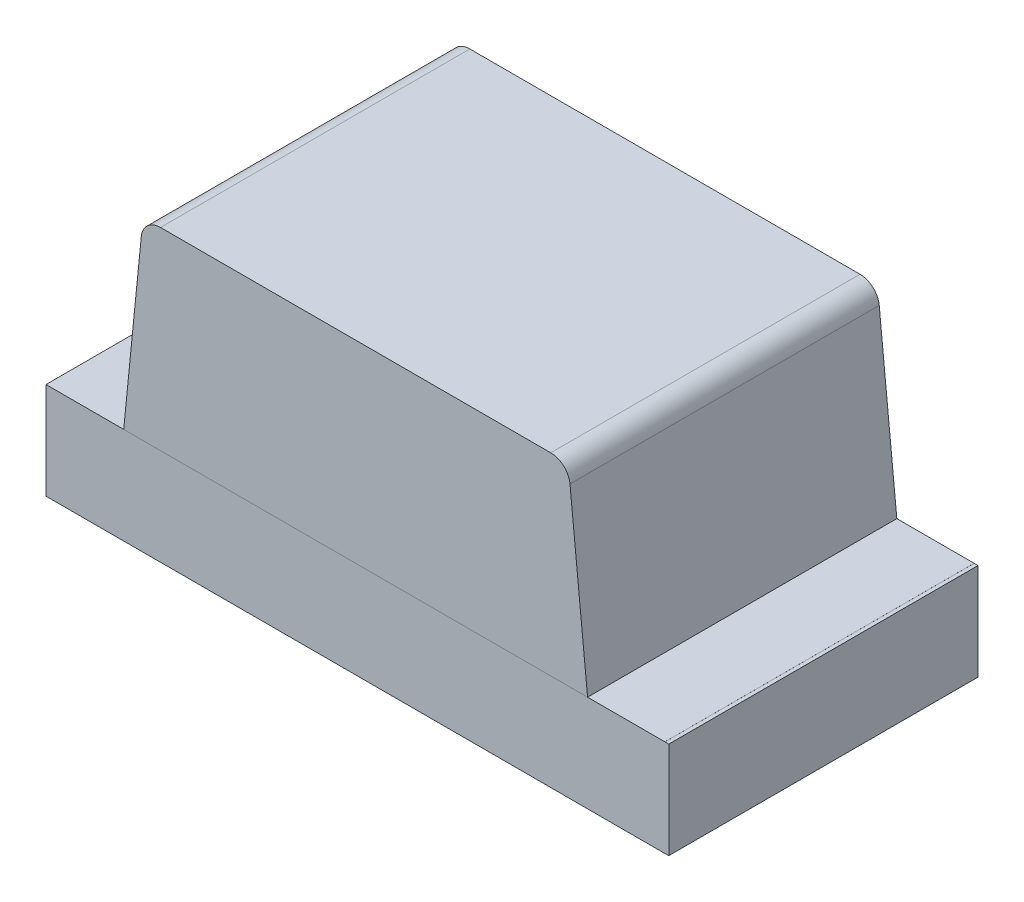
from build123d import *

# Parameters (mm, degrees)
SKETCH1_W             = 1.6
SKETCH1_H             = 0.25
EXTRUDE1_DEPTH        = 0.4
EXTRUDE2_DEPTH        = 0.4
EXTRUDE3_DEPTH        = 0.0001
EXTRUDE3_DEPTH_BACK   = 0.01
SKETCH2_3_W           = 0.3
SKETCH2_3_H           = 0.8
EXTRUDE4_DEPTH        = 0.0001
EXTRUDE4_DEPTH_BACK   = 0.01
EXTRUDE4_2_DEPTH      = 0.0001
EXTRUDE4_2_DEPTH_BACK = 0.01
SKETCH3_W             = 0.2
SKETCH3_H             = 0.8
EXTRUDE5_DEPTH        = 0.0001
EXTRUDE5_DEPTH_BACK   = 0.01
EXTRUDE5_2_DEPTH      = 0.0001
EXTRUDE5_2_DEPTH_BACK = 0.01
FILLET1_R             = 0.05
SKETCH5_W             = 0.8
SKETCH5_H             = 0.25
EXTRUDE6_DEPTH        = 0.01
EXTRUDE6_DEPTH_BACK   = 0.0001
SKETCH6_W             = 0.8
SKETCH6_H             = 0.2502
EXTRUDE7_DEPTH        = 0.001
EXTRUDE7_DEPTH_BACK   = 0.01
SKETCH7_W             = 0.013291139
SKETCH7_H             = 0.012658227
SKETCH7_H_2           = 0.012658228
CUT_EXTRUDE1_DEPTH    = 0.01


with BuildPart() as part:
    # Sketch1 → Extrude1 (new, symmetric)
    with BuildSketch(Plane.XY):
        Rectangle(SKETCH1_W, SKETCH1_H)
    extrude(amount=EXTRUDE1_DEPTH, both=True)



with BuildPart() as body_2:
    # Sketch1_3 → Extrude2 (new, symmetric)
    with BuildSketch(Plane.XY):
        Polygon((-0.55, 0.625), (-0.6, 0.125), (0.6, 0.125), (0.55, 0.625), align=None)
    extrude(amount=EXTRUDE2_DEPTH, both=True)

    # Fillet1
    fillet1_edges = [body_2.edges().sort_by_distance(p)[0] for p in [
        (-0.55, 0.625, 0),
        (0.55, 0.625, 0),
    ]]
    fillet(fillet1_edges, radius=FILLET1_R)


with BuildPart() as body_3:
    # Sketch2 → Extrude3 (new, two sides)
    with BuildSketch(Plane.XZ.offset(0.125)) as extrude3_sk:
        Polygon((-0.339833711, 0.4), (-0.339833711, -0.4), (0.32532124, 0), align=None)
    extrude(amount=EXTRUDE3_DEPTH)
    extrude(extrude3_sk.sketch, amount=-EXTRUDE3_DEPTH_BACK)


with BuildPart() as body_4:
    # Sketch2_3 → Extrude4 (new, two sides)
    with BuildSketch(Plane.XZ.offset(0.125)) as extrude4_sk:
        with Locations((-0.65, 0)):
            Rectangle(SKETCH2_3_W, SKETCH2_3_H)
    extrude(amount=EXTRUDE4_DEPTH)
    extrude(extrude4_sk.sketch, amount=-EXTRUDE4_DEPTH_BACK)


with BuildPart() as body_5:
    # Sketch2_3 → Extrude4 2 (new, two sides)
    with BuildSketch(Plane.XZ.offset(0.125)) as extrude4_2_sk:
        with Locations((0.65, 0)):
            Rectangle(SKETCH2_3_W, SKETCH2_3_H)
    extrude(amount=EXTRUDE4_2_DEPTH)
    extrude(extrude4_2_sk.sketch, amount=-EXTRUDE4_2_DEPTH_BACK)


with BuildPart() as body_6:
    # Sketch3 → Extrude5 (new, two sides)
    with BuildSketch(Plane(origin=(0, 0.125, 0), x_dir=(-1, 0, 0), z_dir=(0, 1, 0))) as extrude5_sk:
        with Locations((0.7, 0)):
            Rectangle(SKETCH3_W, SKETCH3_H)
    extrude(amount=EXTRUDE5_DEPTH)
    extrude(extrude5_sk.sketch, amount=-EXTRUDE5_DEPTH_BACK)


with BuildPart() as body_7:
    # Sketch3 → Extrude5 2 (new, two sides)
    with BuildSketch(Plane(origin=(0, 0.125, 0), x_dir=(-1, 0, 0), z_dir=(0, 1, 0))) as extrude5_2_sk:
        with Locations((-0.7, 0)):
            Rectangle(SKETCH3_W, SKETCH3_H)
    extrude(amount=EXTRUDE5_2_DEPTH)
    extrude(extrude5_2_sk.sketch, amount=-EXTRUDE5_2_DEPTH_BACK)


with BuildPart() as part_1:
    add(part.part)

    add(body_5.part)  # Extrude6 merges body 5

    add(body_7.part)  # Extrude6 merges body 7
    # Sketch5 → Extrude6 (add, two sides)
    with BuildSketch(Plane(origin=(0.8, 0, 0), x_dir=(0, 0, -1), z_dir=(1, 0, 0))) as extrude6_sk:
        Rectangle(SKETCH5_W, SKETCH5_H)
    extrude(amount=EXTRUDE6_DEPTH)
    extrude(extrude6_sk.sketch, amount=-EXTRUDE6_DEPTH_BACK)


    add(body_4.part)  # Extrude7 merges body 4

    add(body_6.part)  # Extrude7 merges body 6
    # Sketch6 → Extrude7 (add, two sides)
    with BuildSketch(Plane.ZY.offset(0.8)) as extrude7_sk:
        Rectangle(SKETCH6_W, SKETCH6_H)
    extrude(amount=EXTRUDE7_DEPTH)
    extrude(extrude7_sk.sketch, amount=-EXTRUDE7_DEPTH_BACK)

    # Sketch7 → Cut-Extrude1 (cut)
    with BuildSketch(Plane.XZ.offset(0.1251)):
        Polygon((-0.707001992, 0.286075949), (-0.744343764, 0.297804589), (-0.744343764, 0.310176028), (-0.719175647, 0.318384098), (-0.744343764, 0.326147152), (-0.744343764, 0.339013054), (-0.707001992, 0.350632911), (-0.707001992, 0.338043908), (-0.732743685, 0.331546677), (-0.707001992, 0.323338608), (-0.707001992, 0.312589003), (-0.732743685, 0.30443038), (-0.707001992, 0.298022152), align=None)
        Polygon((-0.707001992, 0.218987342), (-0.744343764, 0.230715981), (-0.744343764, 0.243087421), (-0.719175647, 0.251295491), (-0.744343764, 0.259058544), (-0.744343764, 0.271924446), (-0.707001992, 0.283544304), (-0.707001992, 0.270955301), (-0.732743685, 0.26445807), (-0.707001992, 0.25625), (-0.707001992, 0.245500396), (-0.732743685, 0.237341772), (-0.707001992, 0.230933544), align=None)
        Polygon((-0.707001992, 0.151898734), (-0.744343764, 0.163627373), (-0.744343764, 0.175998813), (-0.719175647, 0.184206883), (-0.744343764, 0.191969937), (-0.744343764, 0.204835839), (-0.707001992, 0.216455696), (-0.707001992, 0.203866693), (-0.732743685, 0.197369462), (-0.707001992, 0.189161392), (-0.707001992, 0.178411788), (-0.732743685, 0.170253165), (-0.707001992, 0.163844937), align=None)
        with Locations((-0.737698195, 0.137974684)):
            Rectangle(SKETCH7_W, SKETCH7_H)
        with BuildLine():
            add(Edge.make_bspline(
                [(-0.728758321, 0.079746835), (-0.729369388, 0.079765085), (-0.73056932, 0.07980092), (-0.732323163, 0.080105713), (-0.733985315, 0.080602697), (-0.735567388, 0.081288866), (-0.737052132, 0.082185594), (-0.738453578, 0.08327723), (-0.73975585, 0.084571671), (-0.740974038, 0.086045073), (-0.742065093, 0.087693545), (-0.74301811, 0.089492402), (-0.743815446, 0.091432415), (-0.744484978, 0.093506521), (-0.744979195, 0.095729794), (-0.745341189, 0.098088543), (-0.745577848, 0.100585257), (-0.745598831, 0.102297046), (-0.745609587, 0.103174446)],
                knots=[0, 0, 0, 0, 0.907312236, 1.78165839, 2.635367075, 3.479697475, 4.336364812, 5.205276731, 6.11257575, 7.058770404, 8.040786331, 9.044147278, 10.078219212, 11.153049307, 12.278104542, 13.457648573, 14.696882856, 16, 16, 16, 16], degree=3))
            add(Edge.make_bspline(
                [(-0.745609587, 0.103174446), (-0.745597551, 0.104183574), (-0.745574239, 0.106138165), (-0.745359939, 0.108969928), (-0.74503687, 0.111603946), (-0.744553599, 0.114051804), (-0.743953216, 0.116354103), (-0.74330757, 0.118570737), (-0.742575363, 0.120711393), (-0.742025284, 0.122097938), (-0.741752783, 0.12278481)],
                knots=[0, 0, 0, 0, 1.203215828, 2.33052265, 3.384689099, 4.366106119, 5.303329643, 6.221311756, 7.118865988, 8, 8, 8, 8], degree=3))
            Line((-0.741752783, 0.12278481), (-0.729786802, 0.12278481))
            Line((-0.729786802, 0.12278481), (-0.729786802, 0.121360759))
            add(Edge.make_bspline(
                [(-0.729786802, 0.121360759), (-0.73032753, 0.120678102), (-0.73140581, 0.119316796), (-0.732787113, 0.11710018), (-0.733988194, 0.114776357), (-0.734975195, 0.112353621), (-0.735768357, 0.109905199), (-0.736315121, 0.10746751), (-0.736688795, 0.105084716), (-0.736729049, 0.103505432), (-0.736748828, 0.10272943)],
                knots=[0, 0, 0, 0, 1.030622468, 2.055194264, 3.087043286, 4.125157485, 5.149848264, 6.130935704, 7.081611712, 8, 8, 8, 8], degree=3))
            add(Edge.make_bspline(
                [(-0.736748828, 0.10272943), (-0.73674838, 0.102515041), (-0.736747423, 0.10205605), (-0.736683001, 0.101322032), (-0.73663642, 0.100492732), (-0.736531811, 0.099603299), (-0.736422519, 0.09870789), (-0.736232359, 0.09788056), (-0.73605144, 0.097128741), (-0.735867351, 0.0966755), (-0.735779682, 0.096459652)],
                knots=[0, 0, 0, 0, 0.806378557, 1.726393851, 2.771014456, 3.931269413, 5.096090628, 6.161710732, 7.124547685, 8, 8, 8, 8], degree=3))
            add(Edge.make_bspline(
                [(-0.735779682, 0.096459652), (-0.73566577, 0.096219758), (-0.735441909, 0.095748317), (-0.735033106, 0.095100857), (-0.734597455, 0.094509521), (-0.734114745, 0.093978791), (-0.733525791, 0.093553657), (-0.732825363, 0.093239557), (-0.732000213, 0.09306801), (-0.731412708, 0.093048363), (-0.731102071, 0.093037975)],
                knots=[0, 0, 0, 0, 1.024407818, 2.013179384, 2.949802342, 3.859052226, 4.77034807, 5.732977883, 6.801339628, 8, 8, 8, 8], degree=3))
            add(Edge.make_bspline(
                [(-0.731102071, 0.093037975), (-0.730829123, 0.093053696), (-0.730292427, 0.093084607), (-0.729528429, 0.093375503), (-0.72881749, 0.093816952), (-0.728187133, 0.094460463), (-0.727608414, 0.095257502), (-0.727123265, 0.09623537), (-0.726683228, 0.09736186), (-0.726474594, 0.098184089), (-0.726365125, 0.098615506)],
                knots=[0, 0, 0, 0, 0.825212765, 1.622611382, 2.449701629, 3.348069183, 4.336544339, 5.428209675, 6.6506027, 8, 8, 8, 8], degree=3))
            add(Edge.make_bspline(
                [(-0.726365125, 0.098615506), (-0.726141255, 0.09959987), (-0.72568266, 0.101616324), (-0.725109106, 0.104690378), (-0.72447607, 0.107755492), (-0.723871299, 0.109734848), (-0.723576359, 0.110700158)],
                knots=[0, 0, 0, 0, 0.976104583, 1.999535498, 3.024395274, 4, 4, 4, 4], degree=3))
            add(Edge.make_bspline(
                [(-0.723576359, 0.110700158), (-0.723399863, 0.111219416), (-0.723056296, 0.1122302), (-0.722475484, 0.113675972), (-0.721840508, 0.115006529), (-0.721162942, 0.116226584), (-0.720425943, 0.117326245), (-0.719659249, 0.11832384), (-0.71883233, 0.119195603), (-0.71796637, 0.119969445), (-0.717040369, 0.120631102), (-0.7160683, 0.121208477), (-0.715038068, 0.121696295), (-0.713957424, 0.122100736), (-0.712817989, 0.122409273), (-0.711629552, 0.122619901), (-0.710387872, 0.122769095), (-0.709540696, 0.122779501), (-0.7091084, 0.12278481)],
                knots=[0, 0, 0, 0, 1.287286806, 2.505824366, 3.654938963, 4.74627059, 5.778586806, 6.75996495, 7.696030012, 8.595059759, 9.482019644, 10.363222407, 11.245851011, 12.154256429, 13.068444161, 14.012503255, 14.985824751, 16, 16, 16, 16], degree=3))
            add(Edge.make_bspline(
                [(-0.7091084, 0.12278481), (-0.708530328, 0.122766159), (-0.707392692, 0.122729454), (-0.70572817, 0.12242874), (-0.704153801, 0.121915445), (-0.70265207, 0.121222413), (-0.701245527, 0.120308099), (-0.699906253, 0.119215702), (-0.698670457, 0.117903678), (-0.697520291, 0.116415118), (-0.696480591, 0.114771425), (-0.695565313, 0.113001934), (-0.694796987, 0.111117289), (-0.69416004, 0.109124516), (-0.693682705, 0.107015281), (-0.693323239, 0.104796665), (-0.693116648, 0.102459771), (-0.693091023, 0.10086406), (-0.693077942, 0.100049446)],
                knots=[0, 0, 0, 0, 0.894990994, 1.761326291, 2.609044902, 3.454222546, 4.315366365, 5.200560057, 6.125081389, 7.100429509, 8.110379559, 9.133447974, 10.182136699, 11.259192205, 12.370181258, 13.528580438, 14.738335141, 16, 16, 16, 16], degree=3))
            add(Edge.make_bspline(
                [(-0.693077942, 0.100049446), (-0.693089037, 0.099215103), (-0.69311121, 0.09754783), (-0.693300199, 0.095057109), (-0.693577813, 0.092576858), (-0.693998666, 0.090144943), (-0.694486874, 0.087799665), (-0.695034772, 0.085593047), (-0.695653754, 0.083553317), (-0.696130927, 0.082266485), (-0.696361169, 0.08164557)],
                knots=[0, 0, 0, 0, 1.065403572, 2.129000689, 3.188532477, 4.251604565, 5.279552602, 6.247508681, 7.154397237, 8, 8, 8, 8], degree=3))
            Line((-0.696361169, 0.08164557), (-0.707634904, 0.08164557))
            Line((-0.707634904, 0.08164557), (-0.707634904, 0.083059731))
            add(Edge.make_bspline(
                [(-0.707634904, 0.083059731), (-0.70723473, 0.083596183), (-0.706416365, 0.084693243), (-0.705374529, 0.086523061), (-0.704395596, 0.088502179), (-0.703553517, 0.090641594), (-0.702823776, 0.092871108), (-0.702314193, 0.095162587), (-0.701993288, 0.097475669), (-0.701956901, 0.099026524), (-0.701938701, 0.099802215)],
                knots=[0, 0, 0, 0, 0.892283326, 1.824742884, 2.804416662, 3.836872171, 4.8899239, 5.931447339, 6.965372909, 8, 8, 8, 8], degree=3))
            add(Edge.make_bspline(
                [(-0.701938701, 0.099802215), (-0.701949427, 0.100350049), (-0.701970878, 0.101445657), (-0.70216622, 0.103079762), (-0.702481667, 0.104700792), (-0.702891308, 0.105721053), (-0.703095742, 0.106230222)],
                knots=[0, 0, 0, 0, 0.999146175, 1.998183711, 3.000980573, 4, 4, 4, 4], degree=3))
            add(Edge.make_bspline(
                [(-0.703095742, 0.106230222), (-0.703196476, 0.106446973), (-0.703397875, 0.106880332), (-0.703784157, 0.107483654), (-0.704248563, 0.108035989), (-0.704774559, 0.108532027), (-0.705352745, 0.108966226), (-0.705990159, 0.109273902), (-0.706671616, 0.109461838), (-0.707139231, 0.109482917), (-0.707377783, 0.109493671)],
                knots=[0, 0, 0, 0, 1.00524851, 2.009826503, 3.004679593, 4.035271301, 5.048246368, 6.034938417, 6.997532266, 8, 8, 8, 8], degree=3))
            add(Edge.make_bspline(
                [(-0.707377783, 0.109493671), (-0.707696866, 0.109476452), (-0.708306604, 0.109443548), (-0.709164502, 0.109140256), (-0.709903719, 0.108647839), (-0.710401179, 0.108067536), (-0.710749898, 0.107508972), (-0.711005153, 0.106991142), (-0.711246832, 0.106386528), (-0.711495567, 0.105700905), (-0.71174116, 0.104932741), (-0.711978934, 0.104078462), (-0.712203582, 0.103137104), (-0.712346677, 0.102479167), (-0.712421296, 0.102136076)],
                knots=[0, 0, 0, 0, 1.173816843, 2.243057204, 3.312297565, 4.415174738, 5.03266065, 5.73970059, 6.541434878, 7.433956553, 8.430083051, 9.515931566, 10.70464786, 12, 12, 12, 12], degree=3))
            add(Edge.make_bspline(
                [(-0.712421296, 0.102136076), (-0.712609327, 0.101219681), (-0.712978766, 0.099419168), (-0.71353051, 0.096718577), (-0.714167994, 0.09396719), (-0.714742396, 0.092134526), (-0.715041945, 0.091178797)],
                knots=[0, 0, 0, 0, 0.995744513, 1.956417928, 2.934277412, 4, 4, 4, 4], degree=3))
            add(Edge.make_bspline(
                [(-0.715041945, 0.091178797), (-0.715201567, 0.09070552), (-0.715513813, 0.089779714), (-0.716056954, 0.088459399), (-0.716643946, 0.087235869), (-0.717264711, 0.086102353), (-0.717936694, 0.085065368), (-0.718648018, 0.084118027), (-0.719411472, 0.083276117), (-0.720218086, 0.082527335), (-0.721073136, 0.081867755), (-0.721992673, 0.081301606), (-0.722967074, 0.080815492), (-0.724010174, 0.080430689), (-0.725107467, 0.080121679), (-0.726273151, 0.079910131), (-0.72749534, 0.079763139), (-0.728332628, 0.079752331), (-0.728758321, 0.079746835)],
                knots=[0, 0, 0, 0, 1.237467875, 2.420686895, 3.535046182, 4.599015201, 5.620884487, 6.594603852, 7.531477383, 8.433220087, 9.318759595, 10.202828513, 11.105163009, 12.01247538, 12.953896178, 13.926381251, 14.945733412, 16, 16, 16, 16], degree=3))
        make_face()
        with BuildLine():
            Line((-0.744343764, 0.033544304), (-0.744343764, 0.04556962))
            Line((-0.744343764, 0.04556962), (-0.740427625, 0.04556962))
            add(Edge.make_bspline(
                [(-0.740427625, 0.04556962), (-0.740831904, 0.046116275), (-0.741611349, 0.047170216), (-0.742651457, 0.048756729), (-0.74353909, 0.050269774), (-0.744318701, 0.051726519), (-0.744906393, 0.053237621), (-0.745320427, 0.054853378), (-0.745570313, 0.05660479), (-0.745596205, 0.057818238), (-0.745609587, 0.058445411)],
                knots=[0, 0, 0, 0, 1.150872466, 2.218865267, 3.209461834, 4.120482262, 5.012764827, 5.946708227, 6.938749913, 8, 8, 8, 8], degree=3))
            add(Edge.make_bspline(
                [(-0.745609587, 0.058445411), (-0.745598228, 0.058953587), (-0.745576107, 0.059943153), (-0.745403669, 0.061381773), (-0.745134843, 0.062735587), (-0.744731047, 0.063993106), (-0.744248146, 0.065175101), (-0.743608167, 0.066243876), (-0.74289308, 0.067245677), (-0.742039557, 0.068136513), (-0.74109069, 0.068944324), (-0.74002446, 0.069635599), (-0.738857998, 0.070224454), (-0.737582071, 0.070695003), (-0.736202919, 0.071072548), (-0.734713295, 0.071334514), (-0.733119731, 0.07149481), (-0.732022166, 0.07151078), (-0.731458084, 0.071518987)],
                knots=[0, 0, 0, 0, 1.109008058, 2.159558935, 3.158726032, 4.116861086, 5.039058877, 5.938775559, 6.82970133, 7.720510853, 8.624361809, 9.544451588, 10.487360536, 11.471068125, 12.508000841, 13.604731202, 14.768976642, 16, 16, 16, 16], degree=3))
            Line((-0.731458084, 0.071518987), (-0.707001992, 0.071518987))
            Line((-0.707001992, 0.071518987), (-0.707001992, 0.059493671))
            Line((-0.707001992, 0.059493671), (-0.725791549, 0.059493671))
            add(Edge.make_bspline(
                [(-0.725791549, 0.059493671), (-0.726249785, 0.059492853), (-0.727126892, 0.059491288), (-0.728379796, 0.059450118), (-0.729513882, 0.059389668), (-0.730534896, 0.059320316), (-0.731458272, 0.059193807), (-0.732291352, 0.059004953), (-0.733051153, 0.05876954), (-0.733504504, 0.058537381), (-0.73372272, 0.058425633)],
                knots=[0, 0, 0, 0, 1.361401701, 2.605856924, 3.723918663, 4.735739235, 5.645738665, 6.489217889, 7.27279937, 8, 8, 8, 8], degree=3))
            add(Edge.make_bspline(
                [(-0.73372272, 0.058425633), (-0.733922077, 0.05831063), (-0.734313997, 0.058084543), (-0.734817086, 0.057624398), (-0.73523922, 0.057085026), (-0.735567234, 0.056446225), (-0.735816709, 0.055702951), (-0.735986827, 0.054838985), (-0.736094578, 0.053846304), (-0.736108532, 0.053141795), (-0.736115916, 0.052768987)],
                knots=[0, 0, 0, 0, 0.849138082, 1.669332372, 2.503455908, 3.370611167, 4.311442699, 5.394692208, 6.621337967, 8, 8, 8, 8], degree=3))
            add(Edge.make_bspline(
                [(-0.736115916, 0.052768987), (-0.736107238, 0.052498345), (-0.736089394, 0.051941887), (-0.735973171, 0.05108623), (-0.735794834, 0.050187942), (-0.735464906, 0.04893065), (-0.734871816, 0.047347337), (-0.734194613, 0.046167686), (-0.73385128, 0.04556962)],
                knots=[0, 0, 0, 0, 0.638127216, 1.312033637, 2.033062677, 2.79661882, 4.375931797, 6, 6, 6, 6], degree=3))
            Line((-0.73385128, 0.04556962), (-0.707001992, 0.04556962))
            Line((-0.707001992, 0.04556962), (-0.707001992, 0.033544304))
            Line((-0.707001992, 0.033544304), (-0.744343764, 0.033544304))
        make_face()
        with BuildLine():
            Line((-0.744343764, -0.015189873), (-0.744343764, -0.003164557))
            Line((-0.744343764, -0.003164557), (-0.725554207, -0.003164557))
            add(Edge.make_bspline(
                [(-0.725554207, -0.003164557), (-0.724789186, -0.0031523), (-0.723263673, -0.003127858), (-0.721382468, -0.002986796), (-0.719961306, -0.002797535), (-0.719042365, -0.002612707), (-0.718268296, -0.002396857), (-0.717825416, -0.002190717), (-0.717623036, -0.002096519)],
                knots=[0, 0, 0, 0, 1.709124929, 3.408128882, 4.211124727, 4.91016634, 5.501986363, 6, 6, 6, 6], degree=3))
            add(Edge.make_bspline(
                [(-0.717623036, -0.002096519), (-0.71742401, -0.001974288), (-0.71703379, -0.001734636), (-0.716527283, -0.001265974), (-0.716112863, -0.000719031), (-0.715772088, -8.3646e-05), (-0.715536797, 0.000661952), (-0.715340182, 0.001520323), (-0.715256728, 0.002513632), (-0.715239148, 0.003217267), (-0.71522984, 0.003589794)],
                knots=[0, 0, 0, 0, 0.86006424, 1.686277094, 2.52783008, 3.38194165, 4.331801563, 5.402842185, 6.624978739, 8, 8, 8, 8], degree=3))
            add(Edge.make_bspline(
                [(-0.71522984, 0.003589794), (-0.715258209, 0.004155705), (-0.715316136, 0.005311252), (-0.715671889, 0.006742349), (-0.716081369, 0.007907651), (-0.716460784, 0.008833913), (-0.716946505, 0.009788229), (-0.717307416, 0.010427935), (-0.717494476, 0.010759494)],
                knots=[0, 0, 0, 0, 1.338371478, 2.732853438, 3.468019217, 4.261884641, 5.099136535, 6, 6, 6, 6], degree=3))
            Line((-0.717494476, 0.010759494), (-0.744343764, 0.010759494))
            Line((-0.744343764, 0.010759494), (-0.744343764, 0.02278481))
            Line((-0.744343764, 0.02278481), (-0.707001992, 0.02278481))
            Line((-0.707001992, 0.02278481), (-0.707001992, 0.010759494))
            Line((-0.707001992, 0.010759494), (-0.710918131, 0.010759494))
            add(Edge.make_bspline(
                [(-0.710918131, 0.010759494), (-0.710515056, 0.01023079), (-0.709730445, 0.009201638), (-0.708710234, 0.007612019), (-0.70781085, 0.00607007), (-0.707054441, 0.004543565), (-0.706451054, 0.002986088), (-0.706045559, 0.001354709), (-0.705773658, -0.000353494), (-0.705748811, -0.001521852), (-0.705736169, -0.002116297)],
                knots=[0, 0, 0, 0, 1.126119141, 2.192057864, 3.198061997, 4.149848529, 5.076251285, 6.021887753, 6.99356175, 8, 8, 8, 8], degree=3))
            add(Edge.make_bspline(
                [(-0.705736169, -0.002116297), (-0.705748864, -0.002614433), (-0.705773646, -0.003586883), (-0.705928501, -0.005004263), (-0.706203833, -0.006339973), (-0.706602748, -0.00758611), (-0.707095554, -0.00875742), (-0.707711311, -0.009838393), (-0.708440523, -0.010834428), (-0.709271024, -0.011748628), (-0.710215887, -0.012564037), (-0.711274519, -0.013272555), (-0.712446068, -0.013862546), (-0.713726222, -0.014347902), (-0.715108777, -0.014735114), (-0.716606759, -0.014992679), (-0.718208849, -0.015169571), (-0.71931687, -0.015182971), (-0.719887673, -0.015189873)],
                knots=[0, 0, 0, 0, 1.08848837, 2.124922927, 3.110950502, 4.063144162, 4.979605775, 5.882838355, 6.774625441, 7.671951181, 8.57587277, 9.494821853, 10.448322275, 11.435533005, 12.482327682, 13.580118324, 14.753386918, 16, 16, 16, 16], degree=3))
            Line((-0.719887673, -0.015189873), (-0.744343764, -0.015189873))
        make_face()
        Polygon((-0.744343764, -0.062658228), (-0.744343764, -0.026582278), (-0.694343764, -0.026582278), (-0.694343764, -0.039240506), (-0.734850093, -0.039240506), (-0.734850093, -0.062658228), align=None)
        Polygon((-0.744343764, -0.106329114), (-0.744343764, -0.070253165), (-0.694343764, -0.070253165), (-0.694343764, -0.106329114), (-0.703837435, -0.106329114), (-0.703837435, -0.082911392), (-0.712698195, -0.082911392), (-0.712698195, -0.10443038), (-0.722191866, -0.10443038), (-0.722191866, -0.082911392), (-0.734850093, -0.082911392), (-0.734850093, -0.106329114), align=None)
        with BuildLine():
            add(Edge.make_bspline(
                [(-0.719393211, -0.164556962), (-0.719967055, -0.164547304), (-0.721103498, -0.164528178), (-0.722785901, -0.164380583), (-0.724418739, -0.16411757), (-0.726010863, -0.163777979), (-0.727550327, -0.163316726), (-0.729054116, -0.16277587), (-0.730506863, -0.162121047), (-0.73190758, -0.16136862), (-0.733243631, -0.160543884), (-0.734503736, -0.15965651), (-0.735695344, -0.15873362), (-0.736792791, -0.157738964), (-0.737813801, -0.156699373), (-0.738759208, -0.155611609), (-0.739610924, -0.154459076), (-0.740122366, -0.153655495), (-0.740378179, -0.15325356)],
                knots=[0, 0, 0, 0, 1.105570398, 2.18947457, 3.250358341, 4.290584537, 5.323553275, 6.344225964, 7.367641686, 8.3905646, 9.405808457, 10.390761353, 11.358902336, 12.307789878, 13.241960776, 14.165076779, 15.082208636, 16, 16, 16, 16], degree=3))
            add(Edge.make_bspline(
                [(-0.740378179, -0.15325356), (-0.740734249, -0.152633946), (-0.741448205, -0.151391556), (-0.7422825, -0.149399639), (-0.742984558, -0.147336898), (-0.74351177, -0.145161705), (-0.743875292, -0.1428382), (-0.744155696, -0.140337495), (-0.744306575, -0.1376337), (-0.744331085, -0.135766253), (-0.744343764, -0.134800237)],
                knots=[0, 0, 0, 0, 0.896288622, 1.797150563, 2.705281913, 3.629615989, 4.602417572, 5.655716007, 6.787320449, 8, 8, 8, 8], degree=3))
            Line((-0.744343764, -0.134800237), (-0.744343764, -0.117088608))
            Line((-0.744343764, -0.117088608), (-0.694343764, -0.117088608))
            Line((-0.694343764, -0.117088608), (-0.694343764, -0.135304589))
            add(Edge.make_bspline(
                [(-0.694343764, -0.135304589), (-0.69435207, -0.136293955), (-0.69436809, -0.138202319), (-0.694576885, -0.140960738), (-0.694875297, -0.143513342), (-0.695337733, -0.145856016), (-0.695895405, -0.148006019), (-0.69657497, -0.149968756), (-0.697324323, -0.151774643), (-0.69796117, -0.152864064), (-0.698269793, -0.153392009)],
                knots=[0, 0, 0, 0, 1.267175336, 2.444223962, 3.542125549, 4.557526608, 5.500936977, 6.385043188, 7.217374394, 8, 8, 8, 8], degree=3))
            add(Edge.make_bspline(
                [(-0.698269793, -0.153392009), (-0.698538063, -0.153817486), (-0.69907152, -0.154663548), (-0.699962446, -0.155864156), (-0.700940485, -0.156978869), (-0.701966394, -0.158043121), (-0.703067837, -0.15903303), (-0.704237191, -0.159954629), (-0.705476238, -0.160806538), (-0.706780972, -0.16158552), (-0.708145998, -0.162295927), (-0.709582528, -0.16289058), (-0.711071793, -0.163415255), (-0.712626274, -0.163818023), (-0.714230192, -0.16416698), (-0.715900864, -0.164384347), (-0.717627108, -0.164527653), (-0.718799553, -0.16454711), (-0.719393211, -0.164556962)],
                knots=[0, 0, 0, 0, 0.964065863, 1.917049184, 2.86229036, 3.805247319, 4.749389377, 5.698846072, 6.657678277, 7.629829384, 8.610569287, 9.604676042, 10.607940105, 11.6349849, 12.681042988, 13.752616828, 14.862056989, 16, 16, 16, 16], degree=3))
        make_face()
        with BuildLine():
            add(Edge.make_bspline(
                [(-0.719314097, -0.151265823), (-0.718911717, -0.151260702), (-0.718122425, -0.151250659), (-0.716964667, -0.151154875), (-0.715849842, -0.151025347), (-0.714782496, -0.15080982), (-0.713752711, -0.150559996), (-0.712773964, -0.150238922), (-0.711834177, -0.149876723), (-0.710945433, -0.149435904), (-0.710091242, -0.148949086), (-0.709298484, -0.148375339), (-0.708542041, -0.14775117), (-0.707828049, -0.147062027), (-0.707175101, -0.146290557), (-0.706560063, -0.145460506), (-0.7059959, -0.144560327), (-0.705665875, -0.143923833), (-0.705498828, -0.143601661)],
                knots=[0, 0, 0, 0, 1.152093354, 2.259898929, 3.325467225, 4.364140538, 5.376172865, 6.358396836, 7.312077728, 8.257828931, 9.196960457, 10.124297759, 11.056236784, 12.004246951, 12.961658638, 13.947279359, 14.960983522, 16, 16, 16, 16], degree=3))
            add(Edge.make_bspline(
                [(-0.705498828, -0.143601661), (-0.705345472, -0.143264213), (-0.705041509, -0.142595365), (-0.704675913, -0.141559954), (-0.704389495, -0.140515262), (-0.704174066, -0.139414463), (-0.704013101, -0.138179583), (-0.703914472, -0.136716792), (-0.703843387, -0.134988837), (-0.703839511, -0.13374548), (-0.703837435, -0.133079509)],
                knots=[0, 0, 0, 0, 0.826967603, 1.639107464, 2.447640171, 3.242670507, 4.14065217, 5.225198036, 6.513753944, 8, 8, 8, 8], degree=3))
            Line((-0.703837435, -0.133079509), (-0.703837435, -0.129746835))
            Line((-0.703837435, -0.129746835), (-0.734850093, -0.129746835))
            Line((-0.734850093, -0.129746835), (-0.734850093, -0.133079509))
            add(Edge.make_bspline(
                [(-0.734850093, -0.133079509), (-0.734847719, -0.133458613), (-0.734843134, -0.134190496), (-0.734821603, -0.135248617), (-0.734798159, -0.136231516), (-0.734739928, -0.137133951), (-0.734703605, -0.137963293), (-0.734614415, -0.138706684), (-0.734543325, -0.139377929), (-0.734409464, -0.140161727), (-0.734201372, -0.14108831), (-0.733862283, -0.14216894), (-0.733437085, -0.143239207), (-0.733094602, -0.143933494), (-0.732921692, -0.144284019)],
                knots=[0, 0, 0, 0, 1.186793418, 2.291178421, 3.313283093, 4.264083014, 5.122158624, 5.910777728, 6.607099052, 7.234812932, 8.398911528, 9.577194775, 10.776795607, 12, 12, 12, 12], degree=3))
            add(Edge.make_bspline(
                [(-0.732921692, -0.144284019), (-0.732750933, -0.144576577), (-0.732414176, -0.14515354), (-0.731847139, -0.145965292), (-0.731243277, -0.146719151), (-0.730599051, -0.147417157), (-0.729904931, -0.148048807), (-0.72917166, -0.148624816), (-0.728397671, -0.149140041), (-0.727300912, -0.149757735), (-0.725785444, -0.150369358), (-0.72380175, -0.15088913), (-0.721621869, -0.151207565), (-0.72010306, -0.151245906), (-0.719314097, -0.151265823)],
                knots=[0, 0, 0, 0, 0.755160452, 1.489275589, 2.205657296, 2.907868421, 3.605098304, 4.296256403, 4.985378686, 5.676536785, 7.100390329, 8.614249252, 10.241231541, 12, 12, 12, 12], degree=3))
        make_face(mode=Mode.SUBTRACT)
        with Locations((-0.737698195, -0.180379747)):
            Rectangle(SKETCH7_W, SKETCH7_H_2)
        with BuildLine():
            add(Edge.make_bspline(
                [(-0.745609587, -0.217701741), (-0.745598682, -0.216906684), (-0.745577276, -0.215346116), (-0.745338817, -0.213060445), (-0.74497997, -0.210877859), (-0.744469516, -0.208804705), (-0.743795768, -0.206847809), (-0.7429693, -0.20501599), (-0.741976708, -0.203312562), (-0.741187104, -0.202283238), (-0.740793527, -0.201770174)],
                knots=[0, 0, 0, 0, 1.123670284, 2.205584497, 3.245308791, 4.249063313, 5.220352711, 6.167273909, 7.086481357, 8, 8, 8, 8], degree=3))
            add(Edge.make_bspline(
                [(-0.740793527, -0.201770174), (-0.74036614, -0.2012943), (-0.739513018, -0.200344393), (-0.738027305, -0.199111426), (-0.736385783, -0.198049884), (-0.734584672, -0.197157107), (-0.732626307, -0.196441646), (-0.730503976, -0.195930079), (-0.728223586, -0.195620456), (-0.726649619, -0.195586873), (-0.725840995, -0.19556962)],
                knots=[0, 0, 0, 0, 0.916457077, 1.82937027, 2.759194969, 3.714948755, 4.706655623, 5.743329475, 6.840637961, 8, 8, 8, 8], degree=3))
            add(Edge.make_bspline(
                [(-0.725840995, -0.19556962), (-0.724989382, -0.195589), (-0.723338842, -0.195626562), (-0.720952748, -0.195958442), (-0.718743908, -0.196493248), (-0.716717954, -0.197262027), (-0.714871358, -0.198227248), (-0.71318544, -0.199359494), (-0.711663978, -0.200669757), (-0.710791259, -0.201673326), (-0.710354445, -0.202175633)],
                knots=[0, 0, 0, 0, 1.171797512, 2.271099083, 3.308930235, 4.294129479, 5.24602549, 6.17106565, 7.084581485, 8, 8, 8, 8], degree=3))
            add(Edge.make_bspline(
                [(-0.710354445, -0.202175633), (-0.709970152, -0.202688568), (-0.709196924, -0.203720634), (-0.708246574, -0.205422386), (-0.707449181, -0.207233994), (-0.706825359, -0.209148779), (-0.706348406, -0.211135184), (-0.705986484, -0.213165013), (-0.705776205, -0.21523814), (-0.705749579, -0.21663324), (-0.705736169, -0.217335839)],
                knots=[0, 0, 0, 0, 0.952130878, 1.915761808, 2.890227217, 3.891541892, 4.905612075, 5.925811839, 6.955400088, 8, 8, 8, 8], degree=3))
            add(Edge.make_bspline(
                [(-0.705736169, -0.217335839), (-0.705744671, -0.217959198), (-0.705761387, -0.219184934), (-0.705922441, -0.220985457), (-0.706189001, -0.222712728), (-0.706558302, -0.224365194), (-0.707004104, -0.225952167), (-0.707523674, -0.227477255), (-0.708090308, -0.228957161), (-0.708532576, -0.229907445), (-0.708752388, -0.230379747)],
                knots=[0, 0, 0, 0, 1.107648782, 2.178012834, 3.209595929, 4.211695017, 5.185427128, 6.137685403, 7.07440854, 8, 8, 8, 8], degree=3))
            Line((-0.708752388, -0.230379747), (-0.719027309, -0.230379747))
            Line((-0.719027309, -0.230379747), (-0.719027309, -0.228708465))
            add(Edge.make_bspline(
                [(-0.719027309, -0.228708465), (-0.718818699, -0.228458693), (-0.718367842, -0.227918875), (-0.717657465, -0.227025667), (-0.716892669, -0.225951196), (-0.716446696, -0.225124428), (-0.716208875, -0.224683544)],
                knots=[0, 0, 0, 0, 0.792826818, 1.713491785, 2.780691913, 4, 4, 4, 4], degree=3))
            add(Edge.make_bspline(
                [(-0.716208875, -0.224683544), (-0.715987896, -0.224219577), (-0.715534966, -0.223268604), (-0.715118549, -0.221990602), (-0.714834686, -0.220894601), (-0.714706475, -0.219985833), (-0.714611695, -0.219019023), (-0.714601941, -0.218351402), (-0.714596929, -0.218008307)],
                knots=[0, 0, 0, 0, 1.332524827, 2.731214173, 3.480270227, 4.267952375, 5.109889624, 6, 6, 6, 6], degree=3))
            add(Edge.make_bspline(
                [(-0.714596929, -0.218008307), (-0.714606704, -0.217625529), (-0.714625647, -0.216883724), (-0.714764175, -0.21580297), (-0.715003304, -0.214793764), (-0.715323354, -0.213842153), (-0.71576716, -0.212973121), (-0.716283979, -0.212159701), (-0.71689688, -0.211413572), (-0.717617351, -0.210753941), (-0.718407315, -0.210157578), (-0.719274373, -0.209647977), (-0.720197673, -0.209191749), (-0.721199897, -0.20884428), (-0.722264285, -0.208564411), (-0.723395845, -0.208369946), (-0.7245956, -0.208248967), (-0.725418754, -0.208235008), (-0.725840995, -0.208227848)],
                knots=[0, 0, 0, 0, 1.087302107, 2.107140881, 3.088415001, 4.030197574, 4.951552271, 5.852940509, 6.764198256, 7.685219758, 8.621679636, 9.570836121, 10.538340132, 11.542450476, 12.578202196, 13.66207107, 14.800746211, 16, 16, 16, 16], degree=3))
            add(Edge.make_bspline(
                [(-0.725840995, -0.208227848), (-0.726273074, -0.208235235), (-0.72711258, -0.208249588), (-0.728333385, -0.208366345), (-0.729474101, -0.208574291), (-0.730536761, -0.208859915), (-0.73151977, -0.209222089), (-0.732418468, -0.209674648), (-0.733246872, -0.210192826), (-0.733978178, -0.210815105), (-0.734636339, -0.211497047), (-0.735204406, -0.212254492), (-0.735678478, -0.213084112), (-0.73608071, -0.213975202), (-0.736369909, -0.214941723), (-0.736588255, -0.215969991), (-0.736732533, -0.217064769), (-0.736743315, -0.217819945), (-0.736748828, -0.218206092)],
                knots=[0, 0, 0, 0, 1.230336593, 2.390482092, 3.487897344, 4.52859895, 5.520747884, 6.465347575, 7.38981449, 8.296085817, 9.192433006, 10.084246191, 10.984321635, 11.908883871, 12.862027947, 13.850751296, 14.901019963, 16, 16, 16, 16], degree=3))
            add(Edge.make_bspline(
                [(-0.736748828, -0.218206092), (-0.736744764, -0.218569019), (-0.736736842, -0.219276532), (-0.736627803, -0.220308905), (-0.736489862, -0.221289359), (-0.736270158, -0.222207129), (-0.735998971, -0.223054762), (-0.735715717, -0.223834974), (-0.735413325, -0.224541197), (-0.735179548, -0.224971874), (-0.735067657, -0.225178006)],
                knots=[0, 0, 0, 0, 1.200823684, 2.340960236, 3.433630075, 4.476504061, 5.46014544, 6.378484521, 7.223905657, 8, 8, 8, 8], degree=3))
            add(Edge.make_bspline(
                [(-0.735067657, -0.225178006), (-0.73485271, -0.225528109), (-0.734436888, -0.226205393), (-0.733736105, -0.227124757), (-0.733028976, -0.227947191), (-0.732550867, -0.228459447), (-0.732318448, -0.228708465)],
                knots=[0, 0, 0, 0, 1.098601379, 2.125273733, 3.088655601, 4, 4, 4, 4], degree=3))
            Line((-0.732318448, -0.228708465), (-0.732318448, -0.230379747))
            Line((-0.732318448, -0.230379747), (-0.742672483, -0.230379747))
            add(Edge.make_bspline(
                [(-0.742672483, -0.230379747), (-0.74289123, -0.229907052), (-0.743328777, -0.228961548), (-0.743905713, -0.227504259), (-0.744389793, -0.226010272), (-0.744841333, -0.224486086), (-0.745185514, -0.222900044), (-0.745432075, -0.221238529), (-0.745582531, -0.21949778), (-0.745600446, -0.218308585), (-0.745609587, -0.217701741)],
                knots=[0, 0, 0, 0, 0.952012952, 1.904254716, 2.862729541, 3.822037426, 4.808956931, 5.82647221, 6.890850784, 8, 8, 8, 8], degree=3))
        make_face()
        with BuildLine():
            add(Edge.make_bspline(
                [(-0.725692657, -0.276582278), (-0.72644511, -0.276569931), (-0.727911843, -0.276545862), (-0.730047738, -0.276276203), (-0.732065737, -0.275869813), (-0.733959341, -0.275283548), (-0.735737979, -0.274543352), (-0.737382875, -0.273617882), (-0.73890949, -0.27253238), (-0.740304432, -0.271286861), (-0.741553687, -0.26988626), (-0.742651314, -0.268349169), (-0.743558035, -0.266662255), (-0.74431408, -0.2648551), (-0.744898698, -0.262912774), (-0.745305056, -0.260835664), (-0.745572791, -0.258627097), (-0.745597117, -0.257107888), (-0.745609587, -0.256329114)],
                knots=[0, 0, 0, 0, 1.120167703, 2.183507516, 3.201345984, 4.182878364, 5.131270247, 6.065524964, 6.98789854, 7.91635504, 8.84481154, 9.778033504, 10.722808862, 11.691211189, 12.691525459, 13.738229926, 14.840575679, 16, 16, 16, 16], degree=3))
            add(Edge.make_bspline(
                [(-0.745609587, -0.256329114), (-0.745597076, -0.255550353), (-0.74557267, -0.254031171), (-0.745305504, -0.251822416), (-0.744896529, -0.249742868), (-0.744318478, -0.247798215), (-0.743555204, -0.245993842), (-0.74265168, -0.244308909), (-0.741553583, -0.242772026), (-0.740304487, -0.241371283), (-0.738909374, -0.240126124), (-0.737383283, -0.239039328), (-0.735735306, -0.238118121), (-0.733963783, -0.237359195), (-0.732063364, -0.236792532), (-0.730048143, -0.236380801), (-0.727911733, -0.236112697), (-0.726445073, -0.236088409), (-0.725692657, -0.236075949)],
                knots=[0, 0, 0, 0, 1.15937715, 2.261678054, 3.308339936, 4.313313916, 5.277148057, 6.221884977, 7.155068972, 8.083487698, 9.011906424, 9.934242473, 10.868459181, 11.818729666, 12.798784262, 13.81658132, 14.879877871, 16, 16, 16, 16], degree=3))
            add(Edge.make_bspline(
                [(-0.725692657, -0.236075949), (-0.724936945, -0.236088511), (-0.72346044, -0.236113053), (-0.721311003, -0.236380738), (-0.719280678, -0.236789747), (-0.717376521, -0.237369763), (-0.715600722, -0.2381279), (-0.713949669, -0.239048412), (-0.712426382, -0.240146646), (-0.711031506, -0.241401395), (-0.709783315, -0.242807292), (-0.708696863, -0.244354258), (-0.707778534, -0.246030217), (-0.707017617, -0.247833817), (-0.706450335, -0.249777095), (-0.706041545, -0.251845566), (-0.705772509, -0.254044263), (-0.705748503, -0.255553632), (-0.705736169, -0.256329114)],
                knots=[0, 0, 0, 0, 1.124034801, 2.196132384, 3.217834281, 4.203147447, 5.152578239, 6.085969439, 7.010345409, 7.941219594, 8.872481455, 9.802010446, 10.748267785, 11.711250247, 12.709230373, 13.754967386, 14.846549946, 16, 16, 16, 16], degree=3))
            add(Edge.make_bspline(
                [(-0.705736169, -0.256329114), (-0.70574853, -0.257114483), (-0.705772597, -0.258643565), (-0.706040698, -0.260865271), (-0.706447201, -0.262952191), (-0.707030399, -0.264901503), (-0.707786106, -0.266714378), (-0.708703434, -0.268394416), (-0.709804463, -0.269930069), (-0.711058041, -0.271323696), (-0.712460742, -0.272563817), (-0.713985554, -0.273648275), (-0.715645412, -0.274551884), (-0.717422846, -0.275292769), (-0.719319731, -0.275878856), (-0.721336783, -0.276289348), (-0.723474282, -0.276542343), (-0.724940347, -0.276568735), (-0.725692657, -0.276582278)],
                knots=[0, 0, 0, 0, 1.167358552, 2.272800965, 3.322628764, 4.326027541, 5.29287265, 6.238482395, 7.166210353, 8.096447471, 9.020151799, 9.945039072, 10.873038967, 11.824425184, 12.804379233, 13.820580988, 14.881633558, 16, 16, 16, 16], degree=3))
        make_face()
        with BuildLine():
            add(Edge.make_bspline(
                [(-0.734939097, -0.261728639), (-0.734689093, -0.261906228), (-0.734180307, -0.262267642), (-0.733330096, -0.262702769), (-0.732419198, -0.263096771), (-0.731404558, -0.263405869), (-0.730253335, -0.263645529), (-0.728926539, -0.263801225), (-0.727408782, -0.263916047), (-0.726332426, -0.263921278), (-0.725761881, -0.263924051)],
                knots=[0, 0, 0, 0, 0.764956307, 1.556776596, 2.379454426, 3.241401993, 4.200532455, 5.312591107, 6.575484591, 8, 8, 8, 8], degree=3))
            add(Edge.make_bspline(
                [(-0.725761881, -0.263924051), (-0.725224441, -0.263915206), (-0.724194762, -0.263898261), (-0.722714881, -0.263805076), (-0.721373168, -0.263630739), (-0.72016447, -0.2633818), (-0.719079126, -0.263076915), (-0.718107945, -0.262713947), (-0.717248644, -0.262294688), (-0.716746028, -0.261951955), (-0.716505552, -0.261787975)],
                knots=[0, 0, 0, 0, 1.337076348, 2.561692668, 3.686680134, 4.69989255, 5.629188848, 6.488203485, 7.276684665, 8, 8, 8, 8], degree=3))
            add(Edge.make_bspline(
                [(-0.716505552, -0.261787975), (-0.716285911, -0.261619326), (-0.715855033, -0.261288481), (-0.71531394, -0.260700455), (-0.714864793, -0.260068176), (-0.714534773, -0.259378025), (-0.714275144, -0.258655442), (-0.714101726, -0.257901279), (-0.713987665, -0.257123703), (-0.713971976, -0.256596534), (-0.713964017, -0.256329114)],
                knots=[0, 0, 0, 0, 1.058684453, 2.076859345, 3.046867319, 4.017860406, 4.996047344, 5.981941452, 6.976284511, 8, 8, 8, 8], degree=3))
            add(Edge.make_bspline(
                [(-0.713964017, -0.256329114), (-0.713969491, -0.256065148), (-0.713980196, -0.255548839), (-0.714070037, -0.254797507), (-0.714217332, -0.254092033), (-0.714426298, -0.253422095), (-0.71472404, -0.252776108), (-0.715152252, -0.252158936), (-0.715689917, -0.251550968), (-0.716115177, -0.251181844), (-0.716337435, -0.250988924)],
                knots=[0, 0, 0, 0, 1.041978199, 2.038073998, 2.982578265, 3.884042198, 4.804014415, 5.778706634, 6.839057036, 8, 8, 8, 8], degree=3))
            add(Edge.make_bspline(
                [(-0.716337435, -0.250988924), (-0.716574748, -0.250822182), (-0.717074049, -0.25047136), (-0.717926309, -0.250029872), (-0.718907269, -0.249664195), (-0.719999139, -0.249318075), (-0.721234713, -0.249058943), (-0.722611352, -0.248858574), (-0.724138566, -0.248758217), (-0.725204675, -0.248742429), (-0.725761881, -0.248734177)],
                knots=[0, 0, 0, 0, 0.706185926, 1.485796665, 2.33004681, 3.254820698, 4.274138656, 5.402098861, 6.642194297, 8, 8, 8, 8], degree=3))
            add(Edge.make_bspline(
                [(-0.725761881, -0.248734177), (-0.726263113, -0.24873875), (-0.727233669, -0.248747606), (-0.728636862, -0.248847063), (-0.729938828, -0.249011401), (-0.731133844, -0.249249723), (-0.732226293, -0.249536845), (-0.733202123, -0.249910582), (-0.734079651, -0.250322319), (-0.734593522, -0.250672488), (-0.734840204, -0.250840585)],
                knots=[0, 0, 0, 0, 1.270915159, 2.460926195, 3.565223763, 4.596447547, 5.549594966, 6.425286377, 7.244063354, 8, 8, 8, 8], degree=3))
            add(Edge.make_bspline(
                [(-0.734840204, -0.250840585), (-0.735048447, -0.251010866), (-0.735459011, -0.251346584), (-0.736001019, -0.251921043), (-0.736431694, -0.252562899), (-0.736796938, -0.253238501), (-0.737061562, -0.253969402), (-0.737249865, -0.254745348), (-0.737357742, -0.255571215), (-0.737373606, -0.256137613), (-0.737381739, -0.256428006)],
                knots=[0, 0, 0, 0, 1.011121112, 1.993489184, 2.956264801, 3.910060304, 4.874908638, 5.87009835, 6.907993364, 8, 8, 8, 8], degree=3))
            add(Edge.make_bspline(
                [(-0.737381739, -0.256428006), (-0.737354948, -0.256928481), (-0.737301487, -0.257927162), (-0.736945661, -0.259134737), (-0.736521021, -0.260038399), (-0.736081393, -0.260658034), (-0.735561624, -0.261236129), (-0.735148635, -0.261562864), (-0.734939097, -0.261728639)],
                knots=[0, 0, 0, 0, 1.48399549, 2.96126462, 3.700919455, 4.439278468, 5.208134679, 6, 6, 6, 6], degree=3))
        make_face(mode=Mode.SUBTRACT)
        with BuildLine():
            Line((-0.717494476, -0.322151899), (-0.744343764, -0.322151899))
            Line((-0.744343764, -0.322151899), (-0.744343764, -0.310126582))
            Line((-0.744343764, -0.310126582), (-0.725415758, -0.310126582))
            add(Edge.make_bspline(
                [(-0.725415758, -0.310126582), (-0.724970741, -0.310123849), (-0.724116925, -0.310118605), (-0.722887118, -0.310102093), (-0.721762816, -0.310061957), (-0.720739717, -0.310008188), (-0.719809984, -0.309914716), (-0.718972566, -0.309759046), (-0.718219803, -0.309548298), (-0.71776933, -0.309344122), (-0.717553812, -0.30924644)],
                knots=[0, 0, 0, 0, 1.339742217, 2.570446543, 3.702449567, 4.726327994, 5.654556215, 6.512888379, 7.288529137, 8, 8, 8, 8], degree=3))
            add(Edge.make_bspline(
                [(-0.717553812, -0.30924644), (-0.717361128, -0.309141477), (-0.716979182, -0.308933415), (-0.716495251, -0.308499392), (-0.716089929, -0.307995238), (-0.715769201, -0.307405157), (-0.71552012, -0.306715815), (-0.715345447, -0.305908255), (-0.715255246, -0.304976326), (-0.715238628, -0.304315182), (-0.71522984, -0.303965585)],
                knots=[0, 0, 0, 0, 0.859345536, 1.703436662, 2.532498256, 3.390183975, 4.328249457, 5.402602062, 6.626559876, 8, 8, 8, 8], degree=3))
            add(Edge.make_bspline(
                [(-0.71522984, -0.303965585), (-0.715241621, -0.303671938), (-0.71526529, -0.303081995), (-0.71538606, -0.302202758), (-0.715637032, -0.301343152), (-0.716055351, -0.300233813), (-0.716663585, -0.298929162), (-0.717224529, -0.297942954), (-0.717494476, -0.297468354)],
                knots=[0, 0, 0, 0, 0.759443456, 1.525737455, 2.286422378, 3.068189154, 4.58910569, 6, 6, 6, 6], degree=3))
            Line((-0.717494476, -0.297468354), (-0.744343764, -0.297468354))
            Line((-0.744343764, -0.297468354), (-0.744343764, -0.285443038))
            Line((-0.744343764, -0.285443038), (-0.707001992, -0.285443038))
            Line((-0.707001992, -0.285443038), (-0.707001992, -0.297468354))
            Line((-0.707001992, -0.297468354), (-0.710918131, -0.297468354))
            add(Edge.make_bspline(
                [(-0.710918131, -0.297468354), (-0.710527391, -0.297978873), (-0.70976873, -0.298970094), (-0.708745762, -0.30047708), (-0.707864045, -0.301954822), (-0.707098766, -0.30340538), (-0.706471075, -0.304878603), (-0.706052692, -0.306425853), (-0.705786532, -0.308047227), (-0.705753161, -0.309156368), (-0.705736169, -0.309721123)],
                knots=[0, 0, 0, 0, 1.136140478, 2.205924536, 3.217129804, 4.176128364, 5.103417168, 6.04061054, 7.002313223, 8, 8, 8, 8], degree=3))
            add(Edge.make_bspline(
                [(-0.705736169, -0.309721123), (-0.705752042, -0.310322745), (-0.705783064, -0.311498573), (-0.706117695, -0.313204533), (-0.706620007, -0.314812477), (-0.707365224, -0.31629048), (-0.708281624, -0.317651552), (-0.709420478, -0.318847043), (-0.710743381, -0.319904312), (-0.711749199, -0.320449376), (-0.712263068, -0.320727848)],
                knots=[0, 0, 0, 0, 1.06605855, 2.083537511, 3.073064962, 4.046068917, 5.009676085, 5.97370914, 6.964773701, 8, 8, 8, 8], degree=3))
            add(Edge.make_bspline(
                [(-0.712263068, -0.320727848), (-0.711774588, -0.321318891), (-0.710822636, -0.322470721), (-0.709551288, -0.324247517), (-0.708424138, -0.325987096), (-0.707469281, -0.327707222), (-0.706696837, -0.329405047), (-0.706144037, -0.331094611), (-0.705802314, -0.332769002), (-0.705757963, -0.333885631), (-0.705736169, -0.334434335)],
                knots=[0, 0, 0, 0, 1.188124574, 2.315425566, 3.384037189, 4.39937427, 5.362203716, 6.270239573, 7.150007311, 8, 8, 8, 8], degree=3))
            add(Edge.make_bspline(
                [(-0.705736169, -0.334434335), (-0.705747857, -0.334925965), (-0.705770597, -0.335882544), (-0.705938245, -0.337273765), (-0.706223614, -0.338572059), (-0.70662074, -0.339783342), (-0.707132449, -0.340904963), (-0.707769363, -0.34193039), (-0.708522454, -0.342857681), (-0.709372357, -0.343704126), (-0.71033953, -0.34444479), (-0.71140336, -0.345096597), (-0.71257887, -0.345620785), (-0.713842927, -0.346073393), (-0.715211566, -0.346414288), (-0.716682865, -0.346659659), (-0.718252876, -0.346808668), (-0.719333544, -0.346826367), (-0.719887673, -0.346835443)],
                knots=[0, 0, 0, 0, 1.099321551, 2.138985818, 3.128101353, 4.067593225, 4.984602876, 5.878565082, 6.75932895, 7.650734189, 8.554641537, 9.477588118, 10.434248276, 11.427530835, 12.477080043, 13.583595796, 14.760951851, 16, 16, 16, 16], degree=3))
            Line((-0.719887673, -0.346835443), (-0.744343764, -0.346835443))
            Line((-0.744343764, -0.346835443), (-0.744343764, -0.334810127))
            Line((-0.744343764, -0.334810127), (-0.725415758, -0.334810127))
            add(Edge.make_bspline(
                [(-0.725415758, -0.334810127), (-0.72496745, -0.334807271), (-0.724107052, -0.334801792), (-0.722873875, -0.334786951), (-0.721749967, -0.334742133), (-0.720730021, -0.33470186), (-0.719803954, -0.33461755), (-0.71896813, -0.334474033), (-0.718222135, -0.33425897), (-0.717769673, -0.334063024), (-0.717553812, -0.333969541)],
                knots=[0, 0, 0, 0, 1.350843832, 2.592553583, 3.715618503, 4.739861077, 5.667890227, 6.515410335, 7.291728161, 8, 8, 8, 8], degree=3))
            add(Edge.make_bspline(
                [(-0.717553812, -0.333969541), (-0.717361308, -0.333867853), (-0.716980179, -0.333666524), (-0.716492694, -0.333241966), (-0.71608739, -0.332736055), (-0.715769725, -0.33213756), (-0.715518493, -0.331435829), (-0.715347771, -0.330617654), (-0.71525404, -0.329673187), (-0.715238259, -0.329005363), (-0.71522984, -0.32864913)],
                knots=[0, 0, 0, 0, 0.846473755, 1.675897046, 2.498822796, 3.361436039, 4.304631926, 5.39613934, 6.611038701, 8, 8, 8, 8], degree=3))
            add(Edge.make_bspline(
                [(-0.71522984, -0.32864913), (-0.715253458, -0.328148643), (-0.715300967, -0.327141884), (-0.715659342, -0.325900195), (-0.716066658, -0.324889301), (-0.716456294, -0.324039328), (-0.716940957, -0.323118735), (-0.717304527, -0.322483685), (-0.717494476, -0.322151899)],
                knots=[0, 0, 0, 0, 1.291138276, 2.597198332, 3.312242316, 4.108946311, 5.012008063, 6, 6, 6, 6], degree=3))
        make_face()
    extrude(amount=-CUT_EXTRUDE1_DEPTH, mode=Mode.SUBTRACT)


solid = Compound([body_2.part, body_3.part, part_1.part])
